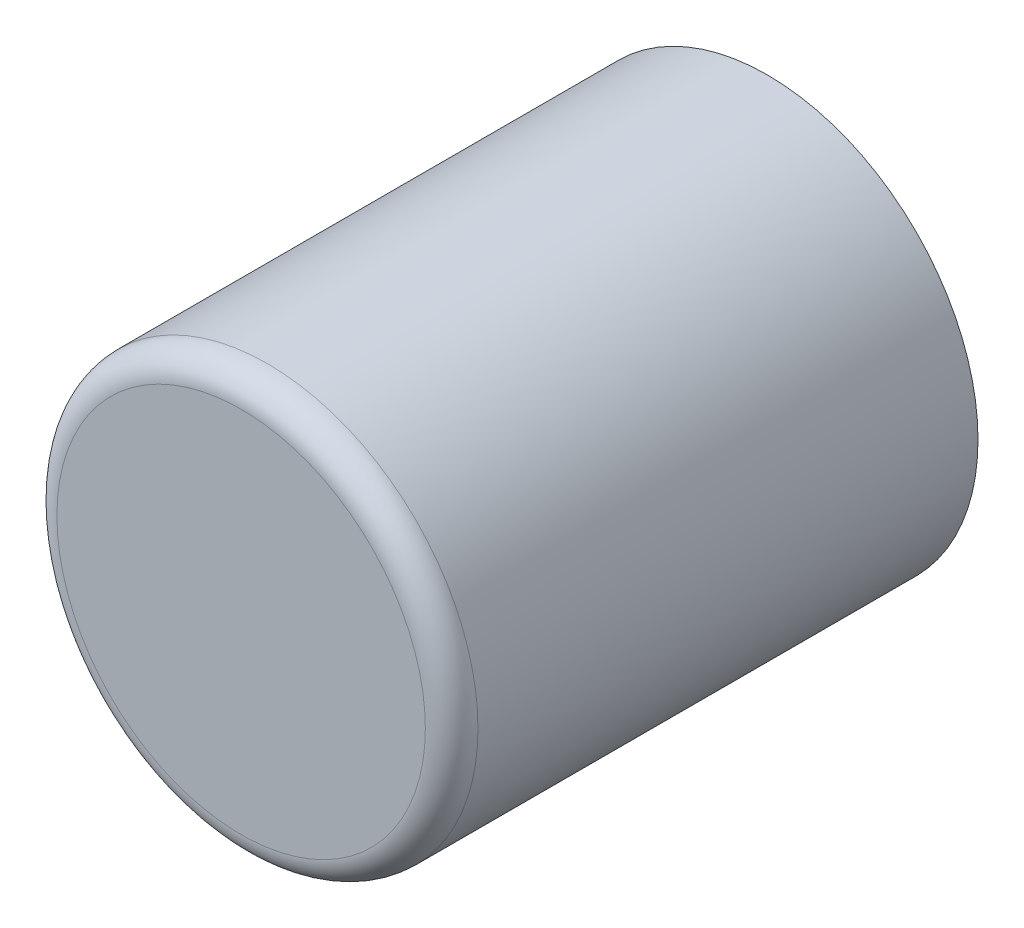
from build123d import *

# Parameters (mm, degrees)
SKETCH1_R      = 4
BASE_DEPTH     = 10
POT_HOLE_DEPTH = 8
FILLET1_R      = 0.5


with BuildPart() as part:
    # Sketch1 → Base (new body)
    with BuildSketch(Plane.XY):
        Circle(SKETCH1_R)
    extrude(amount=BASE_DEPTH)

    # Sketch2 → Pot Hole (cut)
    with BuildSketch(Plane(origin=(0, 0, 0), x_dir=(-1, 0, 0), z_dir=(0, 0, -1))):
        with BuildLine():
            Line((-2.598076211, -1.5), (2.598076211, -1.5))
            ThreePointArc((2.598076211, -1.5), (0, 3), (-2.598076211, -1.5))
        make_face()
    extrude(amount=-POT_HOLE_DEPTH, mode=Mode.SUBTRACT)

    # Fillet1
    fillet1_edges = [part.edges().sort_by_distance(p)[0] for p in [
        (-4, 0, 10),
    ]]
    fillet(fillet1_edges, radius=FILLET1_R)


solid = part.part
